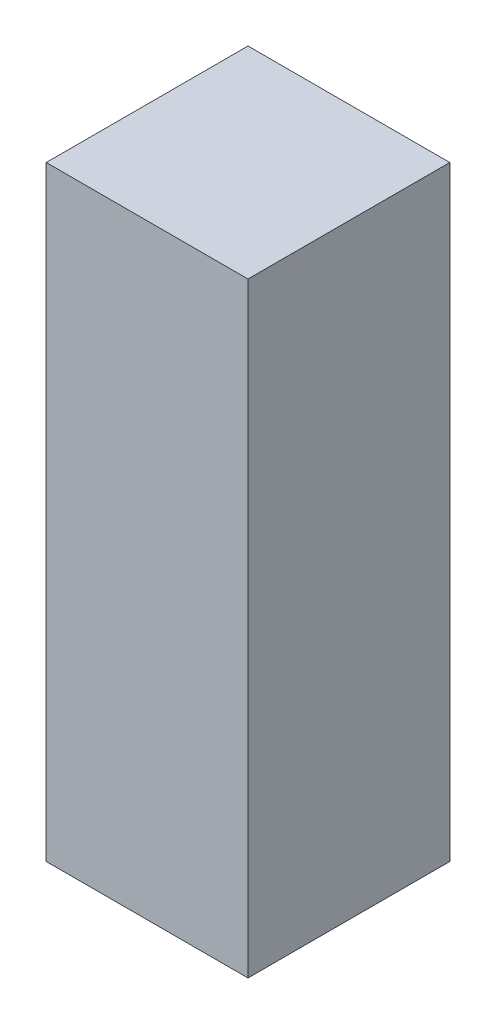
from build123d import *

# Parameters (mm, degrees)
SKETCH1_W  = 10
SKETCH1_H  = 30
BODY_DEPTH = 10


with BuildPart() as part:
    # Sketch1 → BODY (new body)
    with BuildSketch(Plane.XY):
        Rectangle(SKETCH1_W, SKETCH1_H)
    extrude(amount=BODY_DEPTH)


solid = part.part
